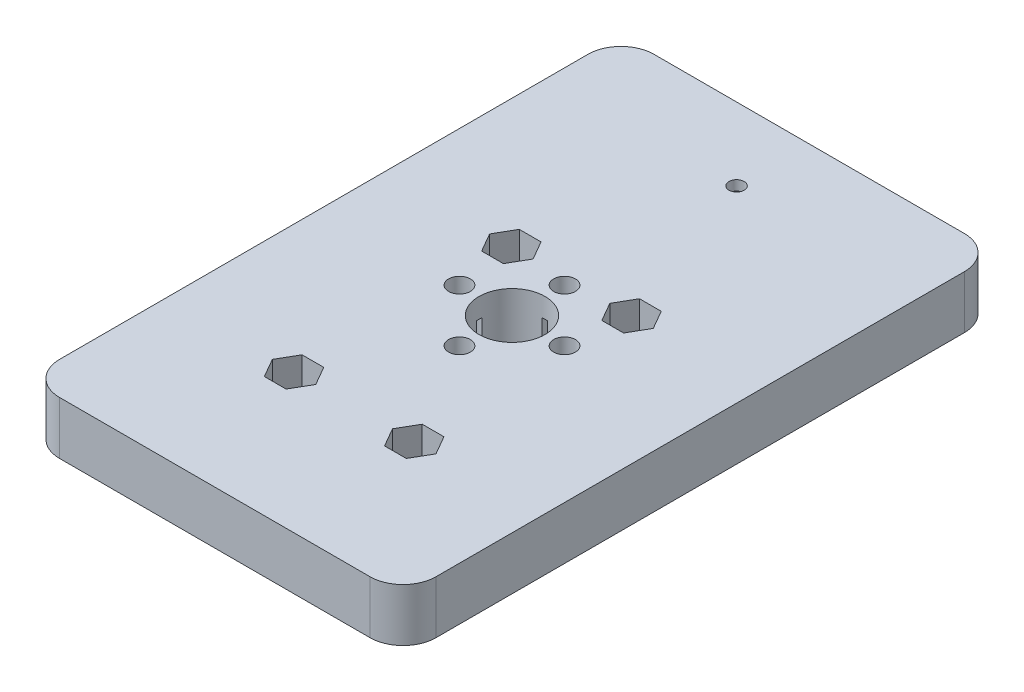
from build123d import *

# Parameters (mm, degrees)
SKETCH_1_W          = 57
SKETCH_1_H          = 90
SKETCH_1_R          = 5
SKETCH_1_R_2        = 1.65
EXTRUDE_1_DEPTH     = 8
CUT_EXTRUDE_1_DEPTH = 5
SKETCH_3_R          = 3
CUT_EXTRUDE_2_DEPTH = 5
FILLET_1_R          = 5
SKETCH_4_R          = 1.15
CUT_EXTRUDE_3_DEPTH = 9
SKETCH_5_R          = 2.15
CUT_EXTRUDE_4_DEPTH = 6.5


with BuildPart() as part:
    # 草图1 → 凸台-拉伸1 (new body)
    with BuildSketch(Plane(origin=(0, 0, 0), x_dir=(1, 0, 0), z_dir=(0, 1, 0))):
        Rectangle(SKETCH_1_W, SKETCH_1_H)
        Circle(SKETCH_1_R, mode=Mode.SUBTRACT)
        with Locations((0, 7.954951288)):
            Circle(SKETCH_1_R_2, mode=Mode.SUBTRACT)
        with Locations((7.954951288, 0)):
            Circle(SKETCH_1_R_2, mode=Mode.SUBTRACT)
        with Locations((0, -7.954951288)):
            Circle(SKETCH_1_R_2, mode=Mode.SUBTRACT)
        with Locations((-7.954951288, 0)):
            Circle(SKETCH_1_R_2, mode=Mode.SUBTRACT)
        with Locations((9.1, 9)):
            Circle(SKETCH_1_R_2, mode=Mode.SUBTRACT)
        with Locations((-9.1, 9)):
            Circle(SKETCH_1_R_2, mode=Mode.SUBTRACT)
        with Locations((-9.1, -23.9)):
            Circle(SKETCH_1_R_2, mode=Mode.SUBTRACT)
        with Locations((9.1, -23.9)):
            Circle(SKETCH_1_R_2, mode=Mode.SUBTRACT)
    extrude(amount=EXTRUDE_1_DEPTH)

    # 草图2 → 切除-拉伸1 (cut)
    with BuildSketch(Plane(origin=(0, 8, 0), x_dir=(1, 0, 0), z_dir=(0, 1, 0))):
        Polygon((-7.454551733, 11.85), (-10.745448267, 11.85), (-12.390896534, 9), (-10.745448267, 6.15), (-7.454551733, 6.15), (-5.809103466, 9), align=None)
        Polygon((10.745448267, 11.85), (7.454551733, 11.85), (5.809103466, 9), (7.454551733, 6.15), (10.745448267, 6.15), (12.390896534, 9), align=None)
        Polygon((10.745448267, -21.05), (7.454551733, -21.05), (5.809103466, -23.9), (7.454551733, -26.75), (10.745448267, -26.75), (12.390896534, -23.9), align=None)
        Polygon((-10.745448267, -21.05), (-12.390896534, -23.9), (-10.745448267, -26.75), (-7.454551733, -26.75), (-5.809103466, -23.9), (-7.454551733, -21.05), align=None)
    extrude(amount=-CUT_EXTRUDE_1_DEPTH, mode=Mode.SUBTRACT)

    # 草图3 → 切除-拉伸2 (cut)
    with BuildSketch(Plane.XZ):
        with Locations((0, 7.954951288)):
            Circle(SKETCH_3_R)
        with Locations((7.954951288, 0)):
            Circle(SKETCH_3_R)
        with Locations((0, -7.954951288)):
            Circle(SKETCH_3_R)
        with Locations((-7.954951288, 0)):
            Circle(SKETCH_3_R)
    extrude(amount=-CUT_EXTRUDE_2_DEPTH, mode=Mode.SUBTRACT)

    # 圆角1
    fillet_1_edges = [part.edges().sort_by_distance(p)[0] for p in [
        (28.5, 4, 45),
        (-28.5, 4, 45),
        (-28.5, 4, -45),
        (28.5, 4, -45),
    ]]
    fillet(fillet_1_edges, radius=FILLET_1_R)

    # 草图4 → 切除-拉伸3 (cut, through all)
    with BuildSketch(Plane(origin=(0, 8, 0), x_dir=(1, 0, 0), z_dir=(0, 1, 0))):
        with Locations((0, 34)):
            Circle(SKETCH_4_R)
    extrude(amount=-CUT_EXTRUDE_3_DEPTH, mode=Mode.SUBTRACT)

    # 草图5 → 切除-拉伸4 (cut)
    with BuildSketch(Plane.XZ):
        with Locations((0, -34)):
            Circle(SKETCH_5_R)
    extrude(amount=-CUT_EXTRUDE_4_DEPTH, mode=Mode.SUBTRACT)


solid = part.part
